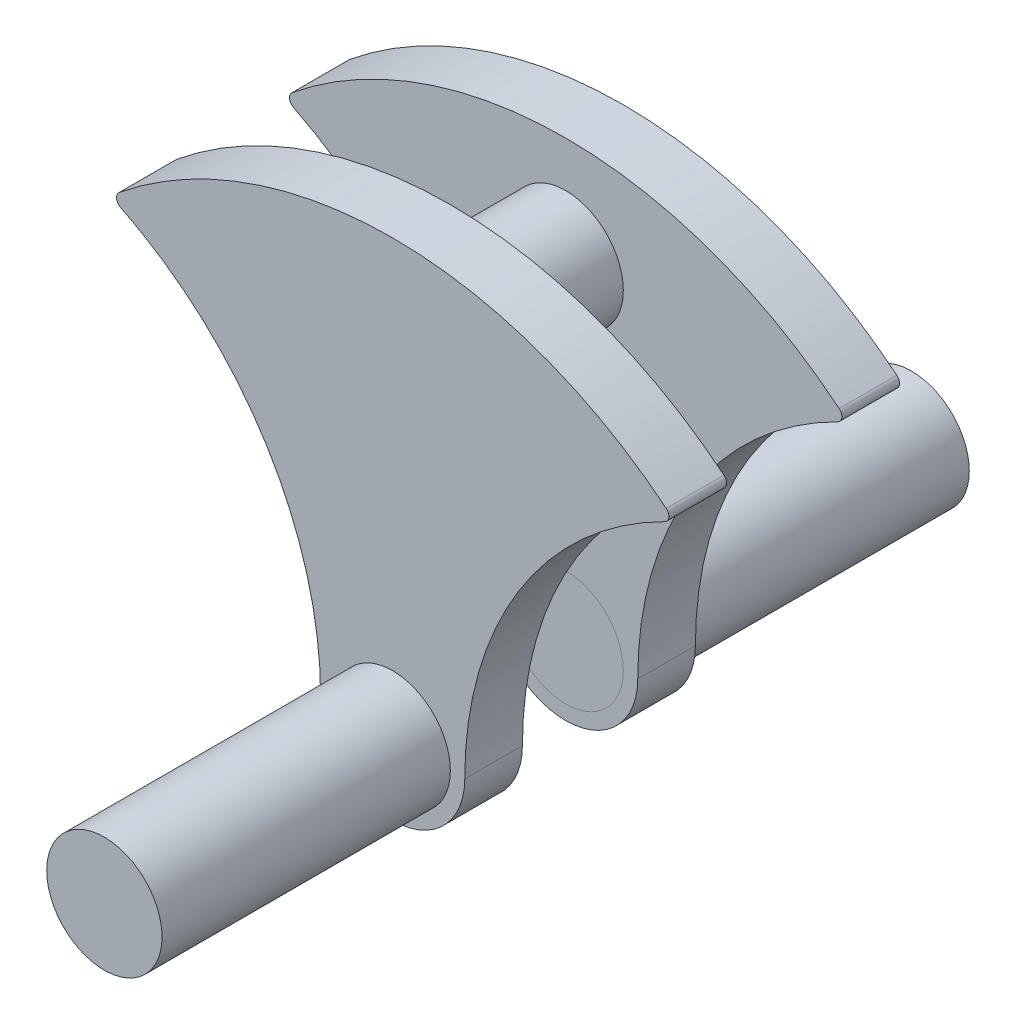
from build123d import *

# Parameters (mm, degrees)
SKETCH1_R                = 20
BOSS_EXTRUDE1_DEPTH      = 20
SKETCH1_5_R              = 20
BOSS_EXTRUDE5_DEPTH      = 80
BOSS_EXTRUDE6_DEPTH      = 20
BOSS_EXTRUDE6_DEPTH_BACK = 100
SKETCH1_7_R              = 20
SKETCH2_R                = 20
BOSS_EXTRUDE7_DEPTH      = 120


with BuildPart() as part:
    # Sketch1 → Boss-Extrude1 (new body)
    with BuildSketch(Plane.XY):
        with BuildLine():
            ThreePointArc((94.866404449, 116.191072407), (0, 150), (-94.866404449, 116.191072407))
            ThreePointArc((-94.866404449, 116.191072407), (-95.784133661, 113.940110793), (-94.389995296, 111.948771216))
            ThreePointArc((-94.389995296, 111.948771216), (-43.754410473, 65.854952023), (-25, 0))
            ThreePointArc((-25, 0), (0, -25), (25, 0))
            ThreePointArc((25, 0), (43.754410473, 65.854952023), (94.389995296, 111.948771216))
            ThreePointArc((94.389995296, 111.948771216), (95.784133661, 113.940110793), (94.866404449, 116.191072407))
        make_face()
        Circle(SKETCH1_R, mode=Mode.SUBTRACT)
        with Locations((0, 114.223570247)):
            Circle(SKETCH1_R, mode=Mode.SUBTRACT)
    boss_extrude1 = extrude(amount=BOSS_EXTRUDE1_DEPTH)

    # Sketch1_5 → Boss-Extrude5 (add)
    with BuildSketch(Plane.XY):
        with Locations((0, 114.223570247)):
            Circle(SKETCH1_5_R)
    extrude(amount=BOSS_EXTRUDE5_DEPTH)

    # Mirror4: Boss-Extrude1 across plane
    add(boss_extrude1.mirror(Plane.XY.offset(40)))

    # Sketch2 → Boss-Extrude7 (add)
    with BuildSketch(Plane(origin=(0, 0, 60), x_dir=(-1, 0, 0), z_dir=(0, 0, -1))):
        Circle(SKETCH2_R)
    extrude(amount=-BOSS_EXTRUDE7_DEPTH)


with BuildPart() as body_2:
    # Sketch1_7 → Boss-Extrude6 (new, two sides: drawn at the far end of the back side and taken through both)
    with BuildSketch(Plane.XY.offset(-BOSS_EXTRUDE6_DEPTH_BACK)):
        Circle(SKETCH1_7_R)
    extrude(amount=BOSS_EXTRUDE6_DEPTH + BOSS_EXTRUDE6_DEPTH_BACK)


solid = Compound([part.part, body_2.part])
